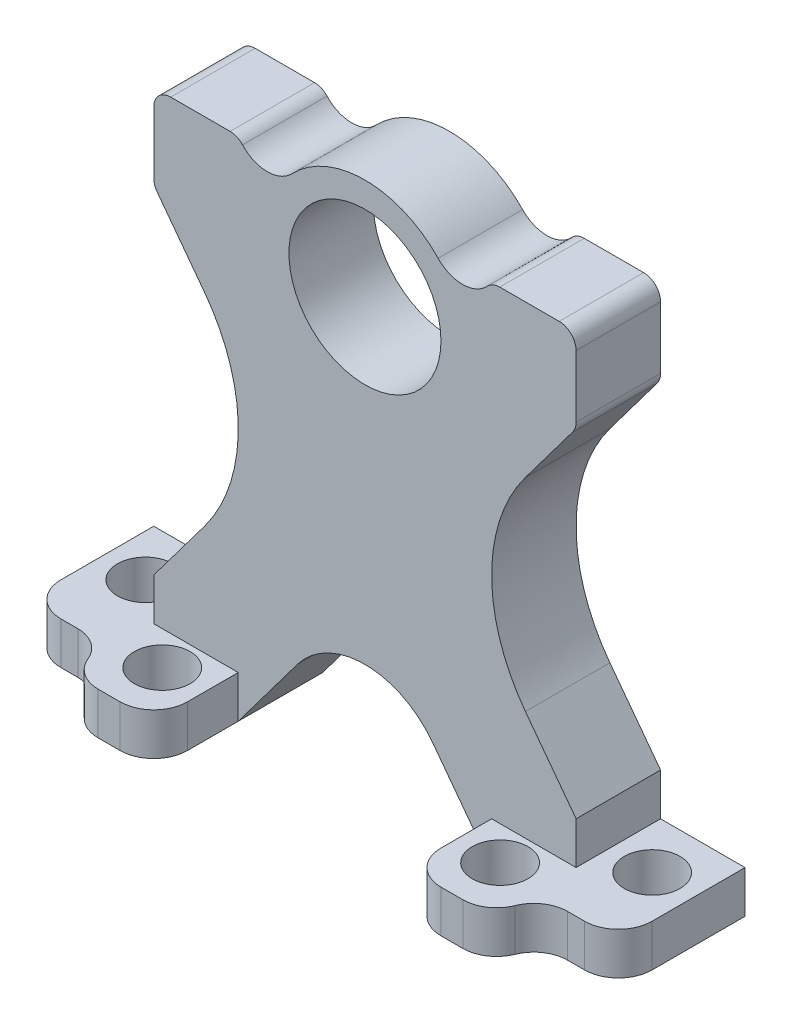
from build123d import *

# Parameters (mm, degrees)
SKETCH1_R           = 4.5
BOSS_EXTRUDE1_DEPTH = 5
SKETCH2_W           = 5
SKETCH2_H           = 2.5
BOSS_EXTRUDE2_DEPTH = 5
SKETCH3_W           = 7.5
SKETCH3_H           = 2.5
BOSS_EXTRUDE3_DEPTH = 5
SKETCH4_W           = 7.5
SKETCH4_H           = 2.5
BOSS_EXTRUDE4_DEPTH = 5
SKETCH5_R           = 1.65
CUT_EXTRUDE1_DEPTH  = 5
FILLET1_R           = 2
FILLET2_R           = 2
FILLET3_R           = 2
FILLET4_R           = 10
FILLET5_R           = 5
FILLET6_R           = 1


with BuildPart() as part:
    # Sketch1 → Boss-Extrude1 (new body)
    with BuildSketch(Plane.XY):
        with BuildLine():
            Line((-7.5, 15), (-5.646592756, 12.528790341))
            ThreePointArc((-5.646592756, 12.528790341), (0, 16.5), (5.646592756, 12.528790341))
            Line((5.646592756, 12.528790341), (7.5, 15))
            Line((7.5, 15), (12.5, 15))
            Line((12.5, 15), (12.5, 10))
            Line((12.5, 10), (5, 0))
            Line((5, 0), (12.5, -10))
            Line((12.5, -10), (12.5, -15))
            Line((12.5, -15), (7.5, -15))
            Line((7.5, -15), (0, -5))
            Line((0, -5), (-7.5, -15))
            Line((-7.5, -15), (-12.5, -15))
            Line((-12.5, -15), (-12.5, -10))
            Line((-12.5, -10), (-5, 0))
            Line((-5, 0), (-12.5, 10))
            Line((-12.5, 10), (-12.5, 15))
            Line((-12.5, 15), (-7.5, 15))
        make_face()
        with Locations((0, 10.5)):
            Circle(SKETCH1_R, mode=Mode.SUBTRACT)
    extrude(amount=BOSS_EXTRUDE1_DEPTH)

    # Sketch2 → Boss-Extrude2 (add)
    with BuildSketch(Plane.XY.offset(5)):
        with Locations((-10, -13.75)):
            Rectangle(SKETCH2_W, SKETCH2_H)
        with Locations((10, -13.75)):
            Rectangle(SKETCH2_W, SKETCH2_H)
    extrude(amount=BOSS_EXTRUDE2_DEPTH)

    # Sketch3 → Boss-Extrude3 (add)
    with BuildSketch(Plane(origin=(12.5, 0, 0), x_dir=(0, 0, -1), z_dir=(1, 0, 0))):
        with Locations((-3.75, -13.75)):
            Rectangle(SKETCH3_W, SKETCH3_H)
    extrude(amount=BOSS_EXTRUDE3_DEPTH)

    # Sketch4 → Boss-Extrude4 (add)
    with BuildSketch(Plane.ZY.offset(12.5)):
        with Locations((3.75, -13.75)):
            Rectangle(SKETCH4_W, SKETCH4_H)
    extrude(amount=BOSS_EXTRUDE4_DEPTH)

    # Sketch5 → Cut-Extrude1 (cut)
    with BuildSketch(Plane(origin=(0, -12.5, 0), x_dir=(1, 0, 0), z_dir=(0, 1, 0))):
        with Locations((-15, -3)):
            Circle(SKETCH5_R)
        with Locations((15, -3)):
            Circle(SKETCH5_R)
        with Locations((-10, -7)):
            Circle(SKETCH5_R)
        with Locations((10, -7)):
            Circle(SKETCH5_R)
    extrude(amount=-CUT_EXTRUDE1_DEPTH, mode=Mode.SUBTRACT)

    # Fillet1
    fillet1_edges = [part.edges().sort_by_distance(p)[0] for p in [
        (12.5, -13.75, 7.5),
        (17.5, -13.75, 7.5),
        (-12.5, -13.75, 7.5),
        (-17.5, -13.75, 7.5),
    ]]
    fillet(fillet1_edges, radius=FILLET1_R)

    # Fillet2
    fillet2_edges = [part.edges().sort_by_distance(p)[0] for p in [
        (12.5, -13.75, 10),
        (7.5, -13.75, 10),
        (-7.5, -13.75, 10),
        (-12.5, -13.75, 10),
    ]]
    fillet(fillet2_edges, radius=FILLET2_R)

    # Fillet3
    fillet3_edges = [part.edges().sort_by_distance(p)[0] for p in [
        (-5.646592756, 12.528790341, 2.5),
        (5.646592756, 12.528790341, 2.5),
    ]]
    fillet(fillet3_edges, radius=FILLET3_R)

    # Fillet4
    fillet4_edges = [part.edges().sort_by_distance(p)[0] for p in [
        (5, 0, 2.5),
        (-5, 0, 2.5),
    ]]
    fillet(fillet4_edges, radius=FILLET4_R)

    # Fillet5
    fillet5_edges = [part.edges().sort_by_distance(p)[0] for p in [
        (0, -5, 2.5),
    ]]
    fillet(fillet5_edges, radius=FILLET5_R)

    # Fillet6
    fillet6_edges = [part.edges().sort_by_distance(p)[0] for p in [
        (-12.5, 10, 2.5),
        (-12.5, 15, 2.5),
        (-7.5, 15, 2.5),
        (12.5, 10, 2.5),
        (7.5, 15, 2.5),
        (12.5, 15, 2.5),
    ]]
    fillet(fillet6_edges, radius=FILLET6_R)


solid = part.part
